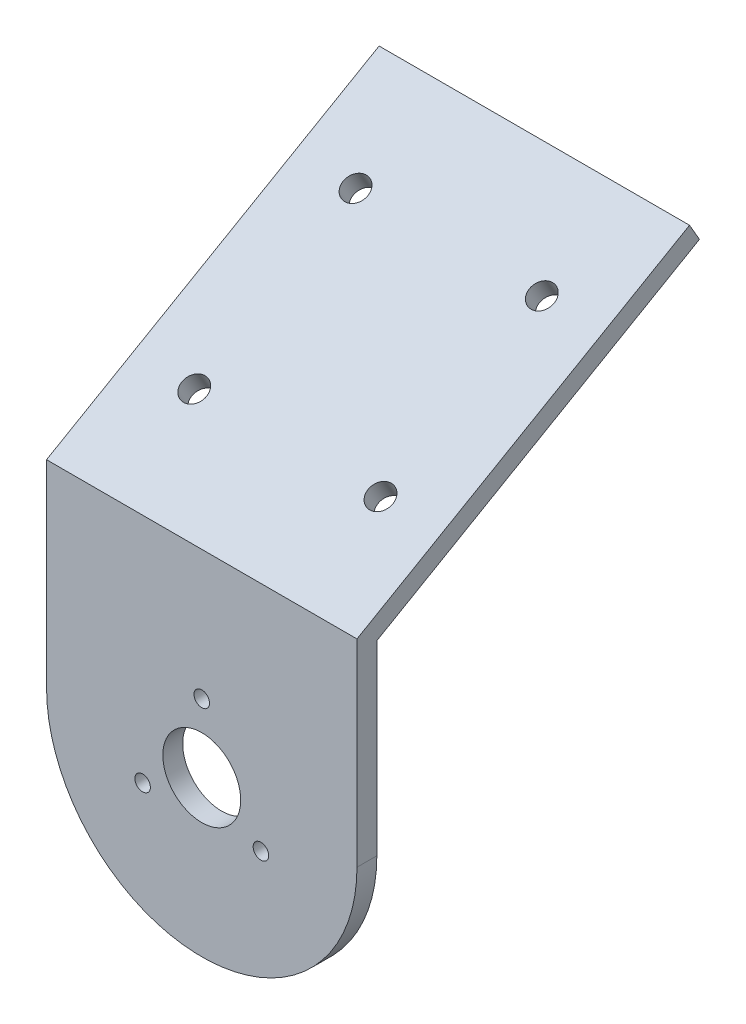
from build123d import *

# Parameters (mm, degrees)
SKETCH1_R           = 6.273243026
SKETCH1_R_2         = 1.25
BOSS_EXTRUDE1_DEPTH = 3.2
BOSS_EXTRUDE2_DEPTH = 50
CUT_EXTRUDE1_REACH  = 78.812
SKETCH3_R           = 2


with BuildPart() as part:
    # Sketch1 → Boss-Extrude1 (new body)
    with BuildSketch(Plane.XY):
        with BuildLine():
            Line((-25, 0), (-25, 30))
            Line((-25, 30), (25, 30))
            Line((25, 30), (25, 0))
            ThreePointArc((25, 0), (0, -25), (-25, 0))
        make_face()
        Circle(SKETCH1_R, mode=Mode.SUBTRACT)
        with Locations((0, 11)):
            Circle(SKETCH1_R_2, mode=Mode.SUBTRACT)
        with Locations((9.526279442, -5.5)):
            Circle(SKETCH1_R_2, mode=Mode.SUBTRACT)
        with Locations((-9.526279442, -5.5)):
            Circle(SKETCH1_R_2, mode=Mode.SUBTRACT)
    extrude(amount=BOSS_EXTRUDE1_DEPTH)

    # Sketch2 → Boss-Extrude2 (add)
    with BuildSketch(Plane(origin=(25, 0, 0), x_dir=(0, 0, -1), z_dir=(1, 0, 0))):
        Polygon((0, 30), (51.961524227, 60), (50.361524227, 62.771281292), (-3.2, 31.847520861), (-3.2, 30), align=None)
    extrude(amount=-BOSS_EXTRUDE2_DEPTH)

    # Sketch3 → Cut-Extrude1 (cut, up to next)
    with BuildSketch(Plane(origin=(0, 25.271281292, 14.590381057), x_dir=(1, 0, 0), z_dir=(0, 0.866025404, 0.5)), mode=Mode.PRIVATE) as cut_extrude1_sk1:
        with Locations((15, 59.076239569)):
            Circle(SKETCH3_R)
    cut_extrude1_tool1 = extrude(cut_extrude1_sk1.sketch, amount=-CUT_EXTRUDE1_REACH, mode=Mode.PRIVATE) & part.part
    add(cut_extrude1_tool1.solids().sort_by_distance((15, 54.809401, -36.571143))[0], mode=Mode.SUBTRACT)
    # Sketch3 → Cut-Extrude1 (cut, up to next)
    with BuildSketch(Plane(origin=(0, 25.271281292, 14.590381057), x_dir=(1, 0, 0), z_dir=(0, 0.866025404, 0.5)), mode=Mode.PRIVATE) as cut_extrude1_sk2:
        with Locations((15, 29.076239569)):
            Circle(SKETCH3_R)
    cut_extrude1_tool2 = extrude(cut_extrude1_sk2.sketch, amount=-CUT_EXTRUDE1_REACH, mode=Mode.PRIVATE) & part.part
    add(cut_extrude1_tool2.solids().sort_by_distance((15, 39.809401, -10.590381))[0], mode=Mode.SUBTRACT)
    # Sketch3 → Cut-Extrude1 (cut, up to next)
    with BuildSketch(Plane(origin=(0, 25.271281292, 14.590381057), x_dir=(1, 0, 0), z_dir=(0, 0.866025404, 0.5)), mode=Mode.PRIVATE) as cut_extrude1_sk3:
        with Locations((-15, 59.076239569)):
            Circle(SKETCH3_R)
    cut_extrude1_tool3 = extrude(cut_extrude1_sk3.sketch, amount=-CUT_EXTRUDE1_REACH, mode=Mode.PRIVATE) & part.part
    add(cut_extrude1_tool3.solids().sort_by_distance((-15, 54.809401, -36.571143))[0], mode=Mode.SUBTRACT)
    # Sketch3 → Cut-Extrude1 (cut, up to next)
    with BuildSketch(Plane(origin=(0, 25.271281292, 14.590381057), x_dir=(1, 0, 0), z_dir=(0, 0.866025404, 0.5)), mode=Mode.PRIVATE) as cut_extrude1_sk4:
        with Locations((-15, 29.076239569)):
            Circle(SKETCH3_R)
    cut_extrude1_tool4 = extrude(cut_extrude1_sk4.sketch, amount=-CUT_EXTRUDE1_REACH, mode=Mode.PRIVATE) & part.part
    add(cut_extrude1_tool4.solids().sort_by_distance((-15, 39.809401, -10.590381))[0], mode=Mode.SUBTRACT)


solid = part.part
